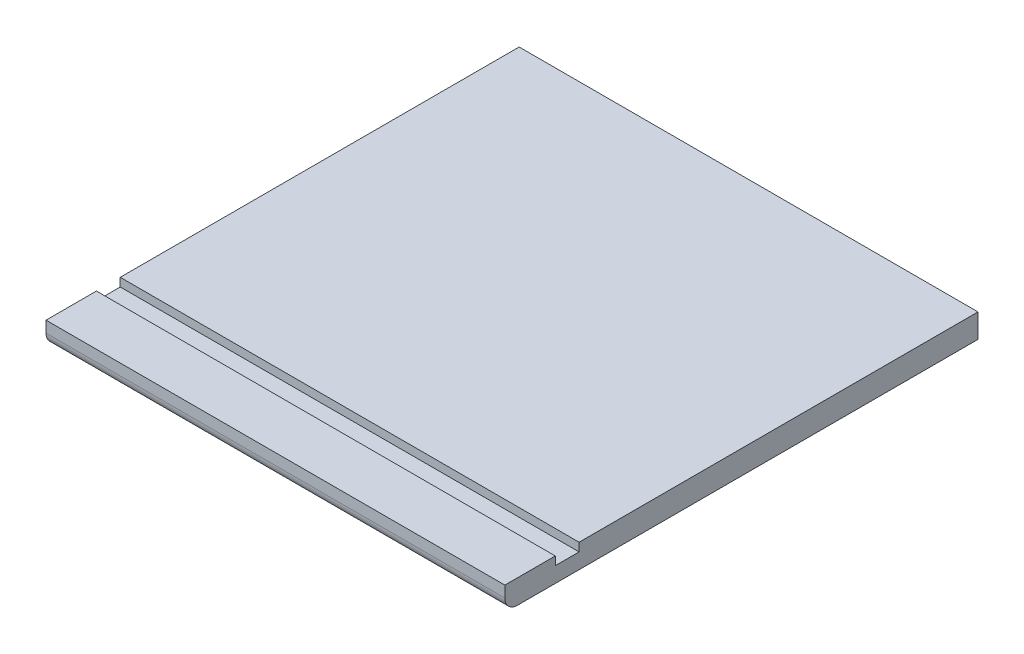
from build123d import *

# Parameters (mm, degrees)
SKETCH1_W           = 346.7
SKETCH1_H           = 357.50000001
BOSS_EXTRUDE1_DEPTH = 18
SKETCH2_W           = 346.7
SKETCH2_H           = 18
CUT_EXTRUDE1_DEPTH  = 6.35
FILLET1_R           = 9.525


with BuildPart() as part:
    # Sketch1 → Boss-Extrude1 (new body)
    with BuildSketch(Plane(origin=(0, 0, 0), x_dir=(1, 0, 0), z_dir=(0, 1, 0))):
        with Locations((173.35, -178.750000005)):
            Rectangle(SKETCH1_W, SKETCH1_H)
    extrude(amount=BOSS_EXTRUDE1_DEPTH)

    # Sketch2 → Cut-Extrude1 (cut)
    with BuildSketch(Plane(origin=(0, 18, 0), x_dir=(1, 0, 0), z_dir=(0, 1, 0))):
        with Locations((173.35, -310.40000001)):
            Rectangle(SKETCH2_W, SKETCH2_H)
    extrude(amount=-CUT_EXTRUDE1_DEPTH, mode=Mode.SUBTRACT)

    # Fillet1
    fillet1_edges = [part.edges().sort_by_distance(p)[0] for p in [
        (173.35, 0, 357.50000001),
    ]]
    fillet(fillet1_edges, radius=FILLET1_R)


solid = part.part
